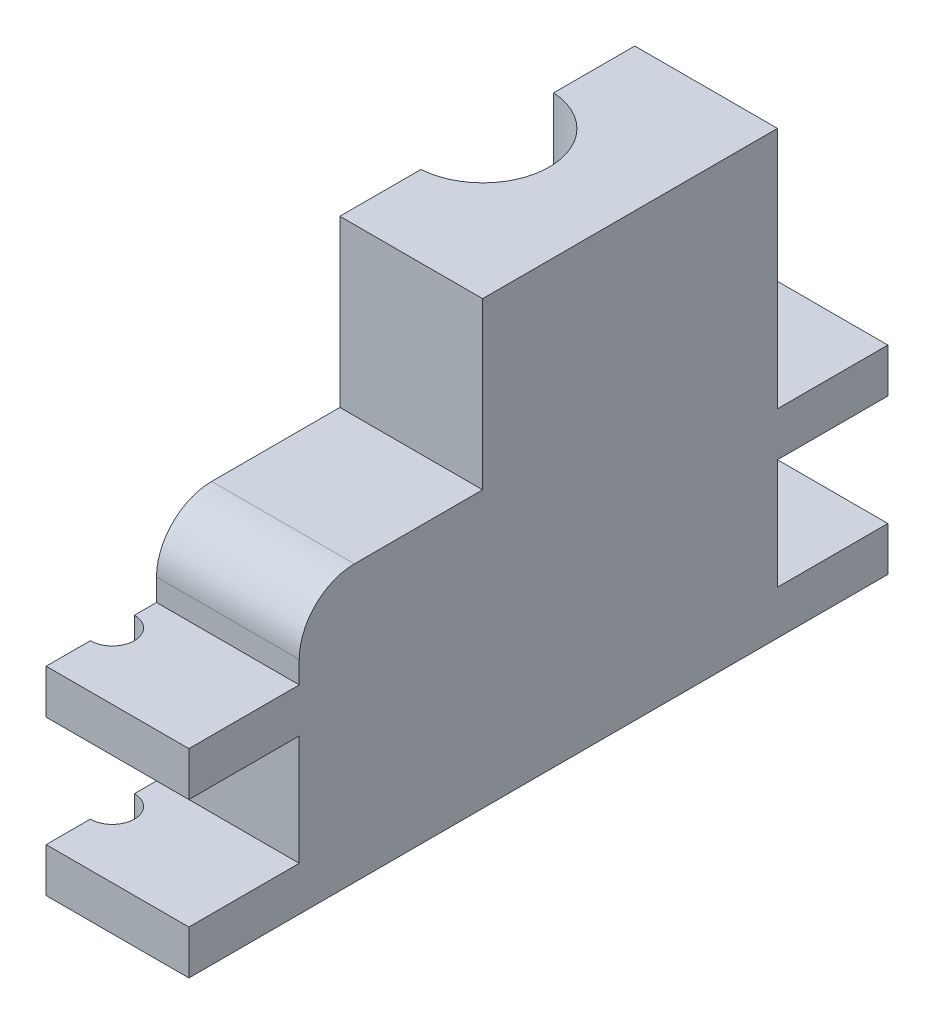
from build123d import *

# Parameters (mm, degrees)
BOSS_EXTRUDE1_DEPTH = 76.2
SKETCH2_R           = 15.24
CUT_EXTRUDE1_DEPTH  = 38.1
SKETCH3_R           = 17.78
CUT_EXTRUDE2_DEPTH  = 6.35
CUT_EXTRUDE3_DEPTH  = 12.7
CUT_EXTRUDE4_DEPTH  = 26.4
SKETCH6_W           = 82.55
SKETCH6_H           = 76.2
CUT_EXTRUDE5_DEPTH  = 0.762
BOSS_EXTRUDE2_DEPTH = 7.62
LPATTERN1_COUNT     = 2
LPATTERN1_PITCH     = 26.67


with BuildPart() as part:
    # Sketch1 → Boss-Extrude1 (new body)
    with BuildSketch(Plane(origin=(0, 0, 0), x_dir=(1, 0, 0), z_dir=(0, 1, 0))):
        with BuildLine():
            Line((0, 0), (0, 45.6184))
            ThreePointArc((0, 45.6184), (11.4808, 57.0992), (0, 68.58))
            Line((0, 68.58), (0, 82.55))
            Line((0, 82.55), (25.4, 82.55))
            Line((25.4, 82.55), (25.4, 0))
            Line((25.4, 0), (0, 0))
        make_face()
    extrude(amount=BOSS_EXTRUDE1_DEPTH)

    # Sketch2 → Cut-Extrude1 (cut)
    with BuildSketch(Plane.XZ):
        with Locations((0, -57.0992)):
            Circle(SKETCH2_R)
    extrude(amount=-CUT_EXTRUDE1_DEPTH, mode=Mode.SUBTRACT)

    # Sketch3 → Cut-Extrude2 (cut)
    with BuildSketch(Plane(origin=(0, 16.51, 0), x_dir=(-1, 0, 0), z_dir=(0, -1, 0))):
        with Locations((0, 57.0992)):
            Circle(SKETCH3_R)
    extrude(amount=-CUT_EXTRUDE2_DEPTH, mode=Mode.SUBTRACT)

    # Sketch4 → Cut-Extrude3 (cut)
    with BuildSketch(Plane.ZY):
        with BuildLine():
            Line((-57.0992, 0), (-12.6492, 0))
            Line((-12.6492, 0), (-12.6492, 15.24))
            ThreePointArc((-12.6492, 15.24), (-19.344738982, 31.404461018), (-35.5092, 38.1))
            Line((-35.5092, 38.1), (-57.0992, 38.1))
            Line((-57.0992, 38.1), (-57.0992, 0))
        make_face()
    extrude(amount=-CUT_EXTRUDE3_DEPTH, mode=Mode.SUBTRACT)

    # Sketch5 → Cut-Extrude4 (cut, through all)
    with BuildSketch(Plane(origin=(25.4, 0, 0), x_dir=(0, 0, -1), z_dir=(1, 0, 0))):
        with BuildLine():
            Line((0, 76.2), (31.6484, 76.2))
            Line((31.6484, 76.2), (31.6484, 47.625))
            Line((31.6484, 47.625), (9.525, 47.625))
            ThreePointArc((9.525, 47.625), (2.789807909, 44.835192091), (0, 38.1))
            Line((0, 38.1), (0, 76.2))
        make_face()
    extrude(amount=-CUT_EXTRUDE4_DEPTH, mode=Mode.SUBTRACT)

    # Sketch6 → Cut-Extrude5 (cut)
    with BuildSketch(Plane.ZY):
        with Locations((-41.275, 38.1)):
            Rectangle(SKETCH6_W, SKETCH6_H)
    extrude(amount=-CUT_EXTRUDE5_DEPTH, mode=Mode.SUBTRACT)

    # Sketch9 → Boss-Extrude2 (add)
    with BuildSketch(Plane.XZ):
        with BuildLine():
            Line((0.762, -12.6492), (25.4, -12.6492))
            Line((25.4, -12.6492), (25.4, 19.05))
            Line((25.4, 19.05), (0.762, 19.05))
            Line((0.762, 19.05), (0.762, 11.43))
            ThreePointArc((0.762, 11.43), (4.572, 7.62), (0.762, 3.81))
            Line((0.762, 3.81), (0.762, -12.6492))
        make_face()
        with BuildLine():
            Line((0.762, -72.320138079), (25.4, -72.320138079))
            Line((25.4, -72.320138079), (25.4, -101.6))
            Line((25.4, -101.6), (0.762, -101.6))
            Line((0.762, -101.6), (0.762, -93.98))
            ThreePointArc((0.762, -93.98), (4.572, -90.17), (0.762, -86.36))
            Line((0.762, -86.36), (0.762, -72.320138079))
        make_face()
    boss_extrude2 = extrude(amount=-BOSS_EXTRUDE2_DEPTH)

    # LPattern1: Boss-Extrude2 ×2
    with Locations(*[(0, i * LPATTERN1_PITCH, 0) for i in range(1, LPATTERN1_COUNT)]):
        add(boss_extrude2)


solid = part.part
